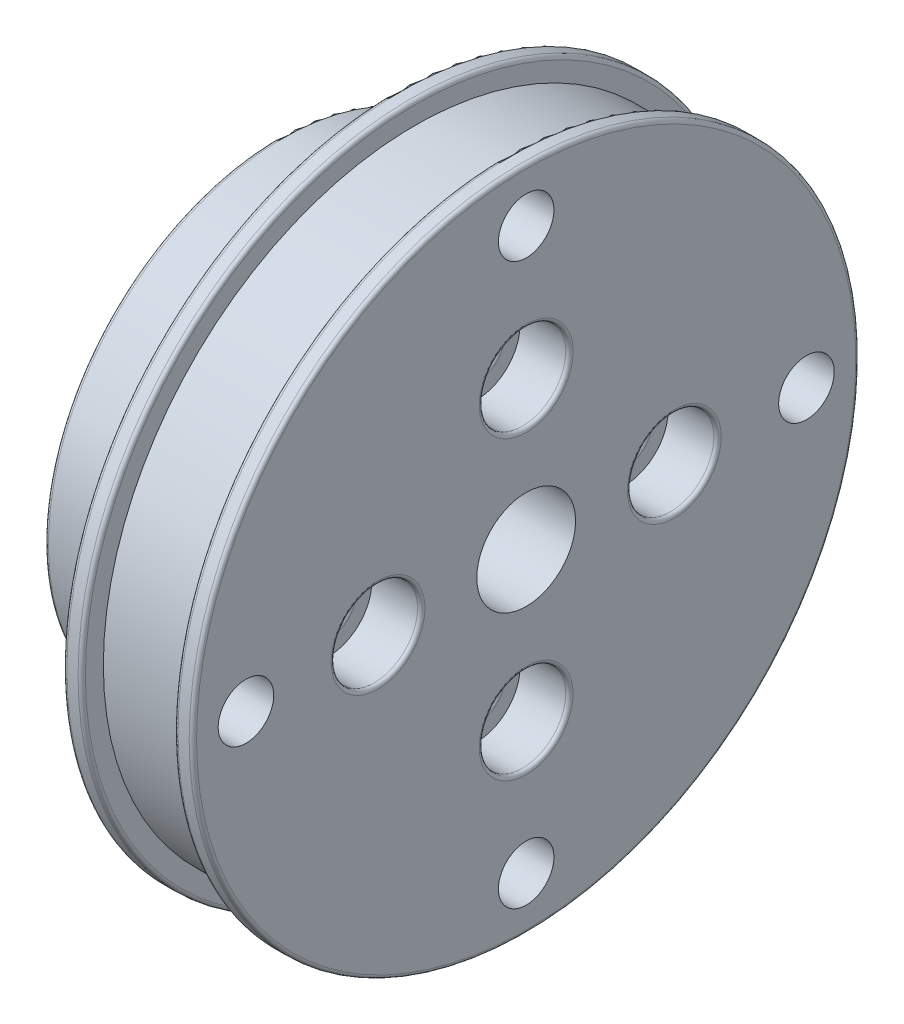
from build123d import *

# Parameters (mm, degrees)
FILLET1_R          = 0.3
SKETCH2_R          = 2
CUT_EXTRUDE1_DEPTH = 44.104524187
SKETCH2_3_R        = 3.5
CUT_EXTRUDE2_DEPTH = 4
FILLET2_R          = 0.3
SKETCH3_R          = 2.25
CUT_EXTRUDE3_DEPTH = 40.601136416


with BuildPart() as part:
    # Sketch1 → Revolve1 (revolve)
    with BuildSketch(Plane(origin=(0, 0, 0), x_dir=(1, 0, 0), z_dir=(0, 1, 0))):
        Polygon((0, 19), (0, 27), (1.5, 27), (1.5, 25.25), (9, 25.25), (9, 27), (10.5, 27), (10.5, 17.5), (10.5, 4), (-9.5, 4), (-9.5, 19), align=None)
    revolve(axis=Axis((0, 0, 0), (1, 0, 0)))

    # Fillet1
    fillet1_edges = [part.edges().sort_by_distance(p)[0] for p in [
        (0, 0, 27),
        (1.5, 0, 27),
        (9, 0, 27),
        (10.5, 0, 27),
    ]]
    fillet(fillet1_edges, radius=FILLET1_R)

    # Sketch2 → Cut-Extrude1 (cut, through all)
    with BuildSketch(Plane(origin=(10.5, 0, 0), x_dir=(0, 0, -1), z_dir=(1, 0, 0))):
        with Locations((-12, 0)):
            Circle(SKETCH2_R)
        with Locations((0, 12)):
            Circle(SKETCH2_R)
        with Locations((12, 0)):
            Circle(SKETCH2_R)
        with Locations((0, -12)):
            Circle(SKETCH2_R)
    extrude(amount=-CUT_EXTRUDE1_DEPTH, mode=Mode.SUBTRACT)

    # Sketch2_3 → Cut-Extrude2 (cut)
    with BuildSketch(Plane(origin=(10.5, 0, 0), x_dir=(0, 0, -1), z_dir=(1, 0, 0))):
        with Locations((-12, 0)):
            Circle(SKETCH2_3_R)
        with Locations((0, 12)):
            Circle(SKETCH2_3_R)
        with Locations((12, 0)):
            Circle(SKETCH2_3_R)
        with Locations((0, -12)):
            Circle(SKETCH2_3_R)
    extrude(amount=-CUT_EXTRUDE2_DEPTH, mode=Mode.SUBTRACT)

    # Fillet2
    fillet2_edges = [part.edges().sort_by_distance(p)[0] for p in [
        (6.5, -12, 2),
        (10.5, -12, 3.5),
        (6.5, 0, -10),
        (10.5, 0, -8.5),
        (6.5, 0, 14),
        (10.5, 0, 15.5),
        (6.5, 12, 2),
        (10.5, 12, 3.5),
        (0, 0, 19),
        (-9.5, 0, 19),
        (-9.5, 0, 4),
        (-9.5, -12, 2),
        (-9.5, 0, -10),
        (-9.5, 12, 2),
        (-9.5, 0, 14),
    ]]
    fillet(fillet2_edges, radius=FILLET2_R)

    # Sketch3 → Cut-Extrude3 (cut, through all)
    with BuildSketch(Plane.ZY):
        with Locations((0, 22.7)):
            Circle(SKETCH3_R)
        with Locations((22.7, 0)):
            Circle(SKETCH3_R)
        with Locations((0, -22.7)):
            Circle(SKETCH3_R)
        with Locations((-22.7, 0)):
            Circle(SKETCH3_R)
    extrude(amount=-CUT_EXTRUDE3_DEPTH, mode=Mode.SUBTRACT)


solid = part.part
